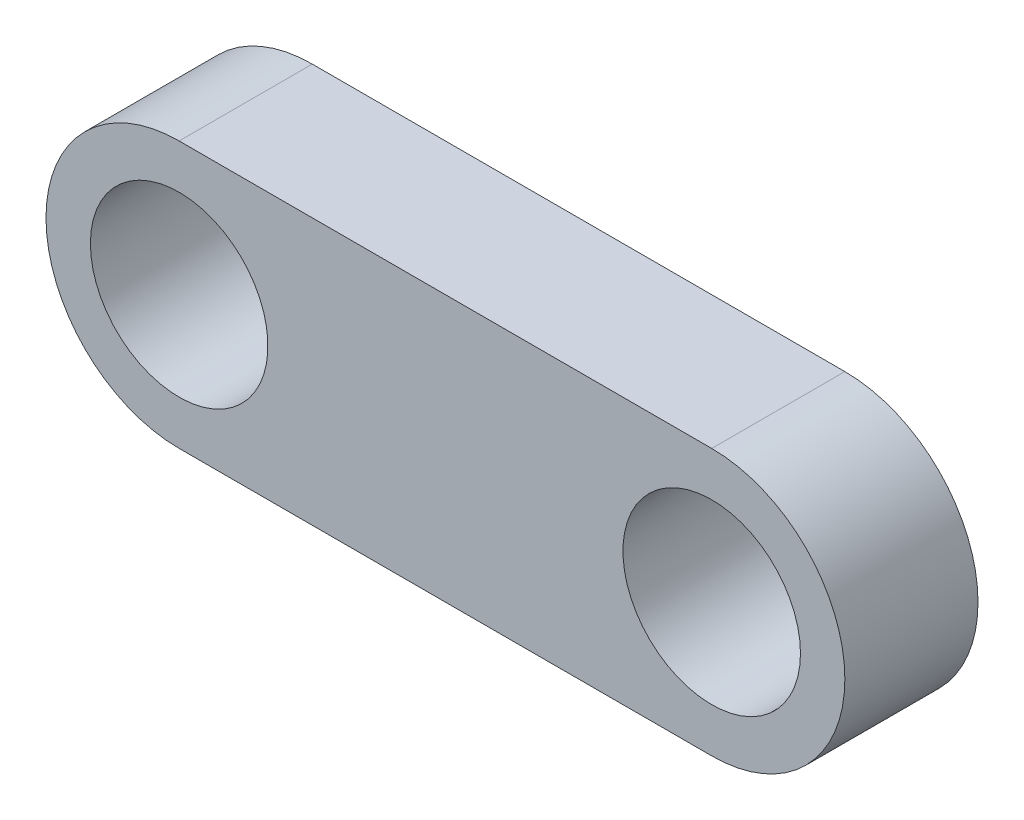
from build123d import *

# Parameters (mm, degrees)
SKETCH1_R           = 4
BOSS_EXTRUDE1_DEPTH = 6


with BuildPart() as part:
    # Sketch1 → Boss-Extrude1 (new body)
    with BuildSketch(Plane.XY):
        with BuildLine():
            Line((-24, 6), (0, 6))
            ThreePointArc((0, 6), (6, 0), (0, -6))
            Line((0, -6), (-24, -6))
            ThreePointArc((-24, -6), (-30, 0), (-24, 6))
        make_face()
        Circle(SKETCH1_R, mode=Mode.SUBTRACT)
        with Locations((-24, 0)):
            Circle(SKETCH1_R, mode=Mode.SUBTRACT)
    extrude(amount=BOSS_EXTRUDE1_DEPTH)


solid = part.part
